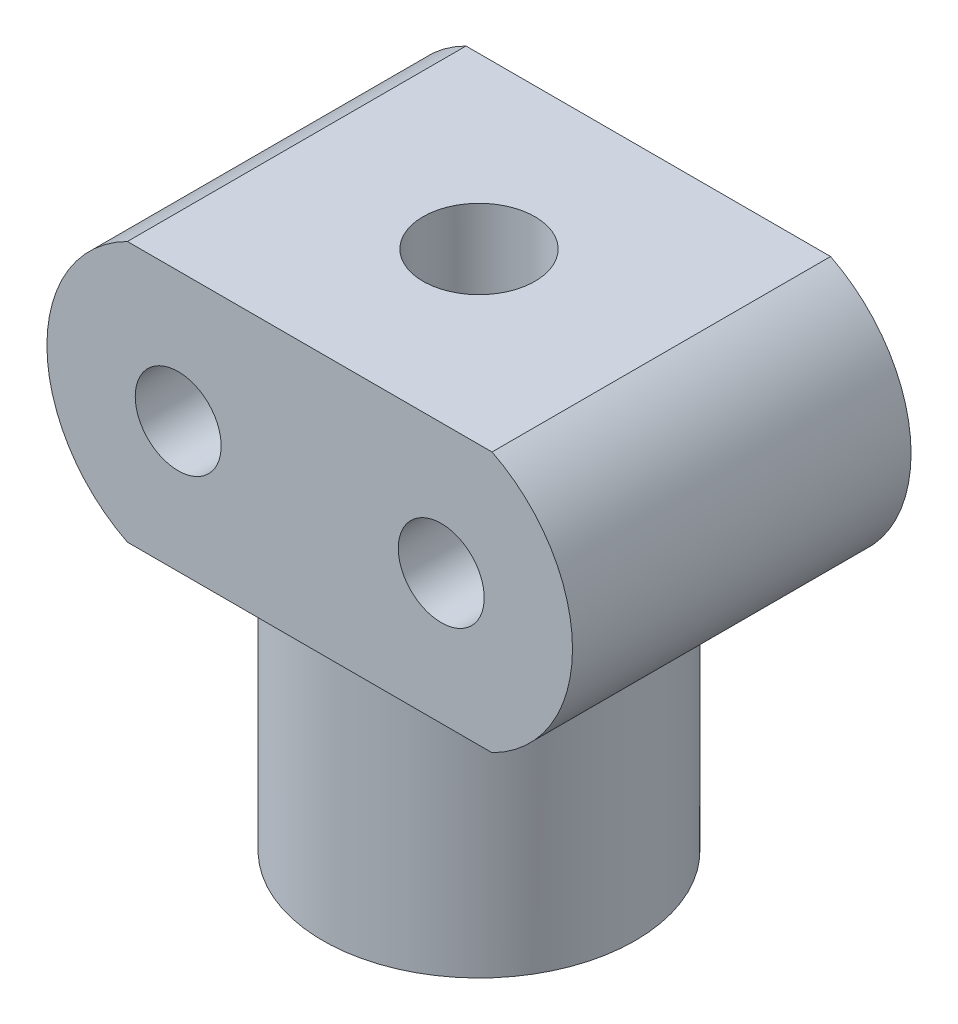
from build123d import *

# Parameters (mm, degrees)
BOSS_EXTRUDE1_DEPTH = 13
SKETCH8_R           = 1.65
CUT_EXTRUDE4_DEPTH  = 14
SKETCH6_R           = 6
BOSS_EXTRUDE2_DEPTH = 10
SKETCH4_R           = 2.15
CUT_EXTRUDE3_DEPTH  = 20


with BuildPart() as part:
    # Sketch2 → Boss-Extrude1 (new body)
    with BuildSketch(Plane.XY):
        with BuildLine():
            Line((7, -5), (-7, -5))
            ThreePointArc((-7, -5), (-10.090169944, 0), (-7, 5))
            Line((-7, 5), (7, 5))
            ThreePointArc((7, 5), (10.090169944, 0), (7, -5))
        make_face()
    extrude(amount=BOSS_EXTRUDE1_DEPTH)

    # Sketch8 → Cut-Extrude4 (cut, through all)
    with BuildSketch(Plane(origin=(0, 0, 0), x_dir=(-1, 0, 0), z_dir=(0, 0, -1))):
        with Locations((-5.05, 0)):
            Circle(SKETCH8_R)
        with Locations((5.05, 0)):
            Circle(SKETCH8_R)
    extrude(amount=-CUT_EXTRUDE4_DEPTH, mode=Mode.SUBTRACT)

    # Sketch6 → Boss-Extrude2 (add)
    with BuildSketch(Plane.XZ.offset(5)):
        with Locations(Location((0, 6.5, 0), (0, 0, 180))):  # turned: the seam where the file's is
            Circle(SKETCH6_R)
    extrude(amount=BOSS_EXTRUDE2_DEPTH)

    # Sketch4 → Cut-Extrude3 (cut)
    with BuildSketch(Plane(origin=(0, 5, 0), x_dir=(1, 0, 0), z_dir=(0, 1, 0))):
        with Locations(Location((0, -6.5, 0), (0, 0, 180))):  # turned: the seam where the file's is
            Circle(SKETCH4_R)
    extrude(amount=-CUT_EXTRUDE3_DEPTH, mode=Mode.SUBTRACT)


solid = part.part
